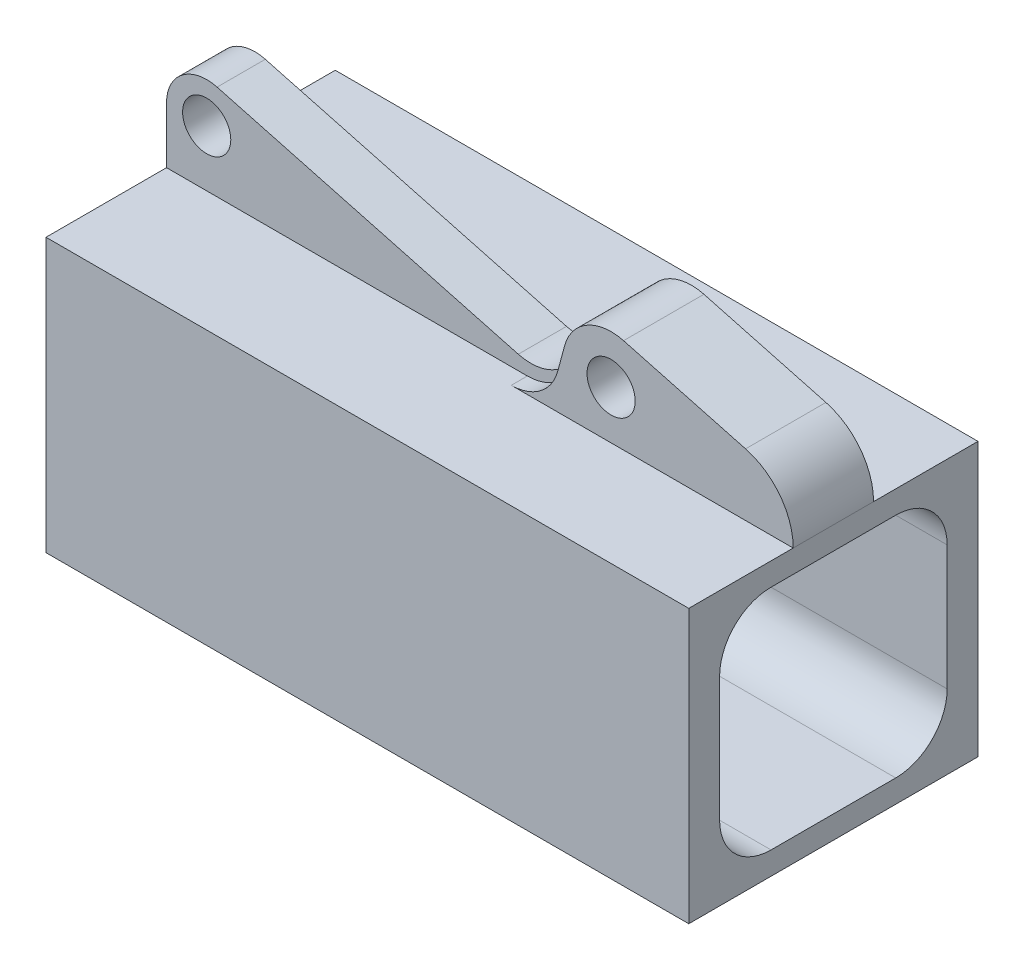
from build123d import *

# Parameters (mm, degrees)
SKETCH1_W           = 28.575
SKETCH1_H           = 26.9875
SKETCH1_W_2         = 22.479
SKETCH1_H_2         = 22.479
BOSS_EXTRUDE1_DEPTH = 31.75
FILLET1_R           = 5.08
SKETCH2_R           = 2.38125
BOSS_EXTRUDE2_DEPTH = 3.96875
SKETCH3_R           = 2.38125
BOSS_EXTRUDE3_DEPTH = 2.38125
FILLET2_R           = 4.7625
FILLET3_R           = 4.7625


with BuildPart() as part:
    # Sketch1 → Boss-Extrude1 (new body, symmetric)
    with BuildSketch(Plane(origin=(0, 0, 0), x_dir=(0, 0, -1), z_dir=(1, 0, 0))):
        Rectangle(SKETCH1_W, SKETCH1_H)
        Rectangle(SKETCH1_W_2, SKETCH1_H_2, mode=Mode.SUBTRACT)
    extrude(amount=BOSS_EXTRUDE1_DEPTH, both=True)

    # Fillet1
    fillet1_edges = [part.edges().sort_by_distance(p)[0] for p in [
        (0, -11.2395, -11.2395),
        (0, 11.2395, -11.2395),
        (0, 11.2395, 11.2395),
        (0, -11.2395, 11.2395),
    ]]
    fillet(fillet1_edges, radius=FILLET1_R)

    # Sketch2 → Boss-Extrude2 (add, symmetric)
    with BuildSketch(Plane.XY):
        with BuildLine():
            Line((7.553126188, 13.49375), (9.159515278, 19.488875702))
            ThreePointArc((9.159515278, 19.488875702), (11.378487026, 22.380695986), (14.992362728, 22.856471748))
            Line((14.992362728, 22.856471748), (27.043500936, 19.627378997))
            ThreePointArc((27.043500936, 19.627378997), (30.437793711, 17.359385074), (31.75, 13.49375))
            Line((31.75, 13.49375), (7.553126188, 13.49375))
        make_face()
        with Locations((13.759737026, 18.25625)):
            Circle(SKETCH2_R, mode=Mode.SUBTRACT)
    extrude(amount=BOSS_EXTRUDE2_DEPTH, both=True)

    # Sketch3 → Boss-Extrude3 (add, symmetric)
    with BuildSketch(Plane.XY):
        with BuildLine():
            ThreePointArc((-31.75, 19.05), (-30.197271921, 22.198621069), (-26.754061915, 22.883518123))
            Line((-26.754061915, 22.883518123), (7.602422382, 13.677725901))
            Line((7.602422382, 13.677725901), (7.553126188, 13.49375))
            Line((7.553126188, 13.49375), (-31.75, 13.49375))
            Line((-31.75, 13.49375), (-31.75, 19.05))
        make_face()
        with Locations((-27.78125, 19.05)):
            Circle(SKETCH3_R, mode=Mode.SUBTRACT)
    extrude(amount=BOSS_EXTRUDE3_DEPTH, both=True)

    # Fillet2
    fillet2_edges = [part.edges().sort_by_distance(p)[0] for p in [
        (7.602422382, 13.677725901, 0),
    ]]
    fillet(fillet2_edges, radius=FILLET2_R)

    # Fillet3
    fillet3_edges = [part.edges().sort_by_distance(p)[0] for p in [
        (7.553126188, 13.49375, 3.175),
        (7.553126188, 13.49375, -3.175),
    ]]
    fillet(fillet3_edges, radius=FILLET3_R)


solid = part.part
